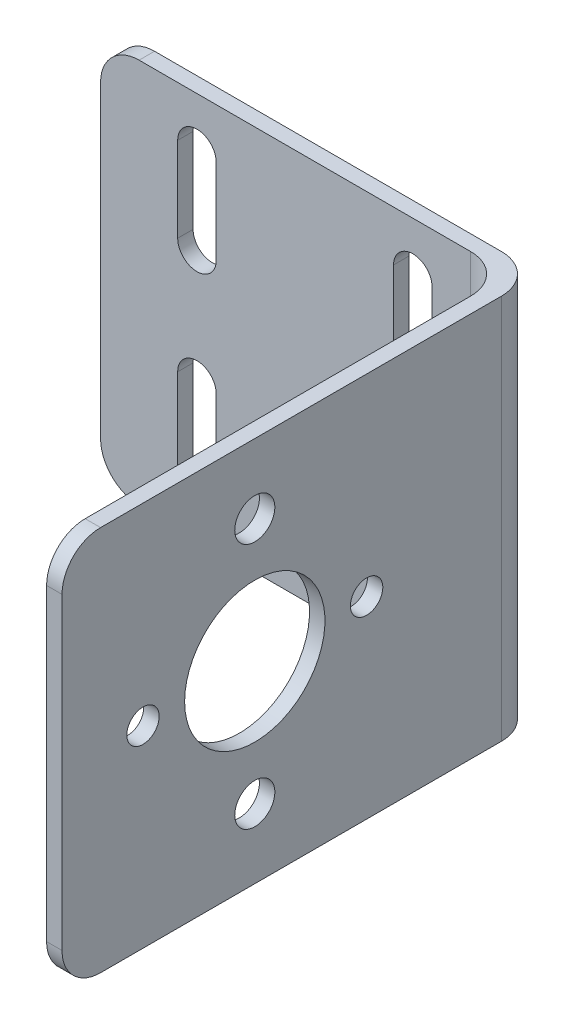
from build123d import *

# Parameters (mm, degrees)
SKETCH1_W           = 50
SKETCH1_H           = 53
BOSS_EXTRUDE1_DEPTH = 2
SKETCH2_W           = 50
SKETCH2_H           = 2
BOSS_EXTRUDE2_DEPTH = 62
SKETCH3_R           = 9.1
SKETCH3_R_2         = 2.6
SKETCH3_R_3         = 2.1
CUT_EXTRUDE1_DEPTH  = 2
CUT_EXTRUDE2_DEPTH  = 2
FILLET1_R           = 5


with BuildPart() as part:
    # Sketch1 → Boss-Extrude1 (new body)
    with BuildSketch(Plane(origin=(0, 0, 0), x_dir=(0, 1, 0), z_dir=(0, 0, 1))):
        Rectangle(SKETCH1_W, SKETCH1_H)
    extrude(amount=BOSS_EXTRUDE1_DEPTH)

    # Sketch2 → Boss-Extrude2 (add)
    with BuildSketch(Plane(origin=(0, 0, 0), x_dir=(0, 1, 0), z_dir=(0, 0, 1))):
        with Locations((0, -27.5)):
            Rectangle(SKETCH2_W, SKETCH2_H)
    extrude(amount=BOSS_EXTRUDE2_DEPTH)

    # Sketch3 → Cut-Extrude1 (cut)
    with BuildSketch(Plane(origin=(26.5, 0, 0), x_dir=(0, -1, 0), z_dir=(-1, 0, 0))):
        with Locations((0, 37)):
            Circle(SKETCH3_R)
        with Locations((16, 37)):
            Circle(SKETCH3_R_2)
        with Locations((-16, 37)):
            Circle(SKETCH3_R_2)
        with Locations((0, 51.5)):
            Circle(SKETCH3_R_3)
        with Locations((0, 22.5)):
            Circle(SKETCH3_R_3)
    extrude(amount=-CUT_EXTRUDE1_DEPTH, mode=Mode.SUBTRACT)

    # Sketch4 → Cut-Extrude2 (cut)
    with BuildSketch(Plane.XY.offset(2)):
        with BuildLine():
            Line((-11.5, 18.5), (-11.5, 7.5))
            ThreePointArc((-11.5, 7.5), (-14, 5), (-16.5, 7.5))
            Line((-16.5, 7.5), (-16.5, 18.5))
            ThreePointArc((-16.5, 18.5), (-14, 21), (-11.5, 18.5))
        make_face()
        with BuildLine():
            Line((-11.5, -7.5), (-11.5, -18.5))
            ThreePointArc((-11.5, -18.5), (-14, -21), (-16.5, -18.5))
            Line((-16.5, -18.5), (-16.5, -7.5))
            ThreePointArc((-16.5, -7.5), (-14, -5), (-11.5, -7.5))
        make_face()
        with BuildLine():
            Line((16.5, 18.5), (16.5, 7.5))
            ThreePointArc((16.5, 7.5), (14, 5), (11.5, 7.5))
            Line((11.5, 7.5), (11.5, 18.5))
            ThreePointArc((11.5, 18.5), (14, 21), (16.5, 18.5))
        make_face()
        with BuildLine():
            Line((16.5, -7.5), (16.5, -18.5))
            ThreePointArc((16.5, -18.5), (14, -21), (11.5, -18.5))
            Line((11.5, -18.5), (11.5, -7.5))
            ThreePointArc((11.5, -7.5), (14, -5), (16.5, -7.5))
        make_face()
    extrude(amount=-CUT_EXTRUDE2_DEPTH, mode=Mode.SUBTRACT)

    # Fillet1
    fillet1_edges = [part.edges().sort_by_distance(p)[0] for p in [
        (28.5, 0, 0),
        (27.5, -25, 62),
        (26.5, 0, 2),
        (27.5, 25, 62),
        (-26.5, -25, 1),
        (-26.5, 25, 1),
    ]]
    fillet(fillet1_edges, radius=FILLET1_R)


solid = part.part
